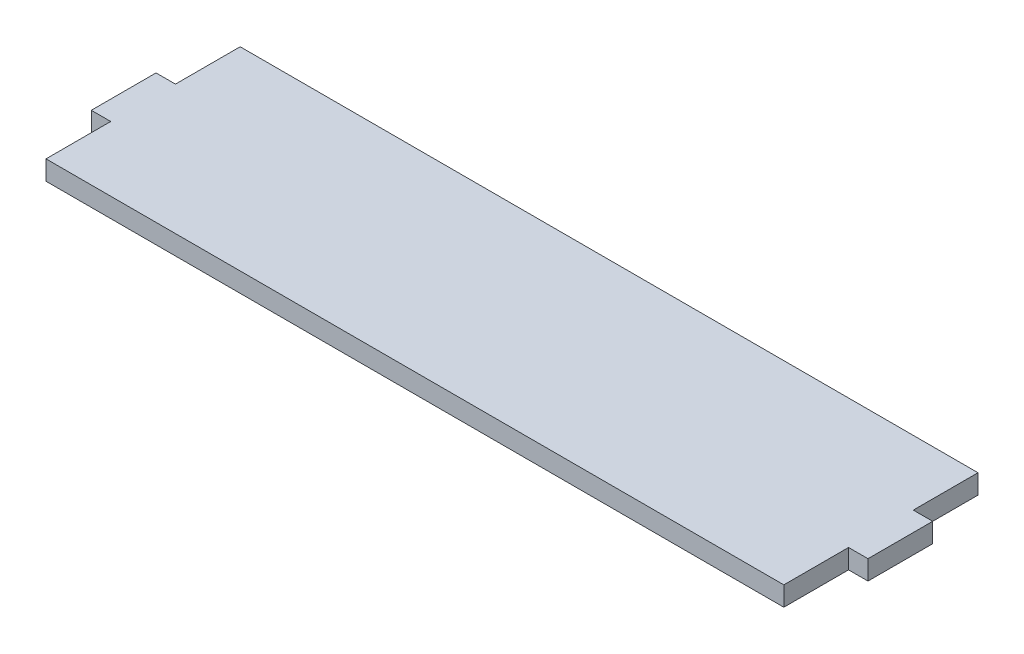
from build123d import *

# Parameters (mm, degrees)
SALIENTE_EXTRUIR1_DEPTH = 3


with BuildPart() as part:
    # Croquis1 → Saliente-Extruir1 (new body)
    with BuildSketch(Plane(origin=(0, 0, 0), x_dir=(1, 0, 0), z_dir=(0, 1, 0))):
        Polygon((-57, 5), (-60, 5), (-60, -5), (-57, -5), (-57, -15), (57, -15), (57, -5), (60, -5), (60, 5), (57, 5), (57, 15), (-57, 15), align=None)
    extrude(amount=SALIENTE_EXTRUIR1_DEPTH)


solid = part.part
